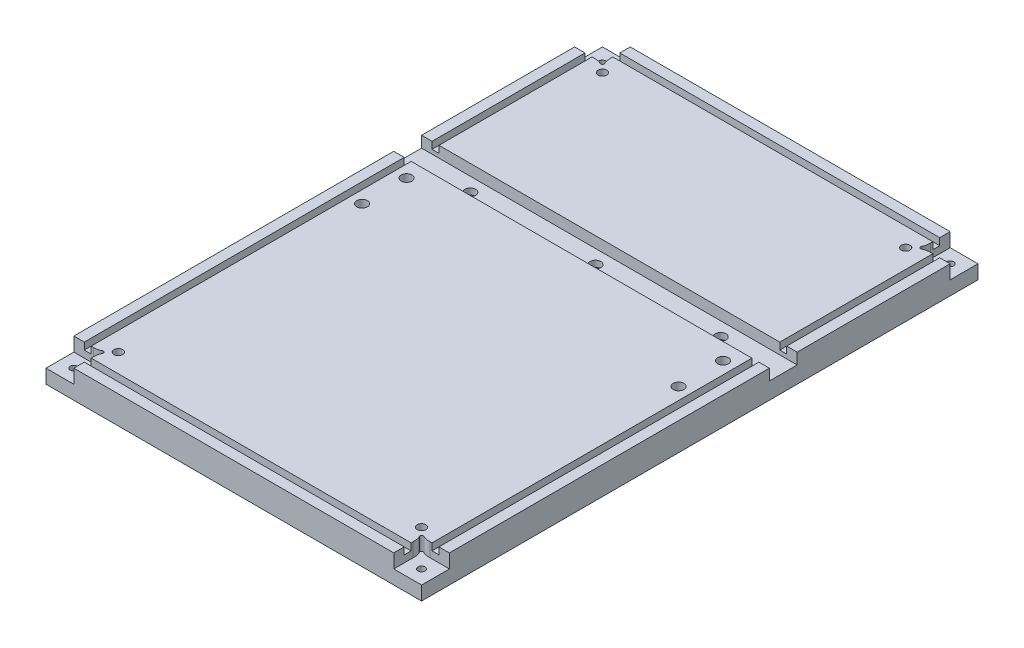
from build123d import *

# Parameters (mm, degrees)
BASE_W                                           = 342.9
BASE_H                                           = 508
BOSS_EXTRUDE1_DEPTH                              = 25.4
SKETCH2_W                                        = 406.4
SKETCH2_H                                        = 25.4
CUT_EXTRUDE1_DEPTH                               = 10.16
CBORE_FOR_3_8_SOCKET_HEAD_CAP_SCREW4_D           = 9.8044
CBORE_FOR_3_8_SOCKET_HEAD_CAP_SCREW4_DEPTH       = 15.24
CBORE_FOR_3_8_SOCKET_HEAD_CAP_SCREW4_CBORE_D     = 15.875
CBORE_FOR_3_8_SOCKET_HEAD_CAP_SCREW4_CBORE_DEPTH = 9.525
CBORE_FOR_3_8_SOCKET_HEAD_CAP_SCREW3_D           = 9.8044
CBORE_FOR_3_8_SOCKET_HEAD_CAP_SCREW3_DEPTH       = 25.4
CBORE_FOR_3_8_SOCKET_HEAD_CAP_SCREW3_CBORE_D     = 15.875
CBORE_FOR_3_8_SOCKET_HEAD_CAP_SCREW3_CBORE_DEPTH = 15.24
CBORE_FOR_1_4_SOCKET_HEAD_CAP_SCREW1_D           = 6.5278
CBORE_FOR_1_4_SOCKET_HEAD_CAP_SCREW1_DEPTH       = 25.4
CBORE_FOR_1_4_SOCKET_HEAD_CAP_SCREW1_CBORE_D     = 11.1125
CBORE_FOR_1_4_SOCKET_HEAD_CAP_SCREW1_CBORE_DEPTH = 6.35
CUT_EXTRUDE3_DEPTH                               = 12.7
SKETCH10_W                                       = 6.35
SKETCH10_H                                       = 457.2
SKETCH10_W_2                                     = 292.1
SKETCH10_H_2                                     = 6.35
CUT_EXTRUDE4_DEPTH                               = 6.35
F_3_8_16_TAPPED_HOLE2_D                          = 7.9375
F_3_8_16_TAPPED_HOLE2_DEPTH                      = 25.4
SKETCH19_R                                       = 9.525
CUT_EXTRUDE5_DEPTH                               = 1.27


with BuildPart() as part:
    # Base → Boss-Extrude1 (new body)
    with BuildSketch(Plane(origin=(0, 0, 0), x_dir=(1, 0, 0), z_dir=(0, 1, 0))):
        with Locations((-30.52641196, -120.249169435)):
            Rectangle(BASE_W, BASE_H)
    extrude(amount=BOSS_EXTRUDE1_DEPTH)

    # Sketch2 → Cut-Extrude1 (cut)
    with BuildSketch(Plane(origin=(0, 25.4, 0), x_dir=(1, 0, 0), z_dir=(0, 1, 0))):
        with Locations((-30.52641196, -44.049169435)):
            Rectangle(SKETCH2_W, SKETCH2_H)
    extrude(amount=-CUT_EXTRUDE1_DEPTH, mode=Mode.SUBTRACT)

    # CBORE for 3/8 Socket Head Cap Screw4
    with Locations(Plane(origin=(83.77358804, 0, 44.049169435), x_dir=(0, 0, -1), z_dir=(0, -1, 0))):
        with Locations((0, 0), (0, -114.3), (0, -228.6)):
            CounterBoreHole(CBORE_FOR_3_8_SOCKET_HEAD_CAP_SCREW4_D / 2, CBORE_FOR_3_8_SOCKET_HEAD_CAP_SCREW4_CBORE_D / 2, CBORE_FOR_3_8_SOCKET_HEAD_CAP_SCREW4_CBORE_DEPTH, depth=CBORE_FOR_3_8_SOCKET_HEAD_CAP_SCREW4_DEPTH)

    # CBORE for 3/8 Socket Head Cap Screw3
    with Locations(Plane(origin=(0, 0, 0), x_dir=(-1, 0, 0), z_dir=(0, -1, 0))):
        with Locations((-113.93608804, -71.989169435), (-113.93608804, -112.629169435), (174.98891196, -71.989169435), (174.98891196, -112.629169435)):
            CounterBoreHole(CBORE_FOR_3_8_SOCKET_HEAD_CAP_SCREW3_D / 2, CBORE_FOR_3_8_SOCKET_HEAD_CAP_SCREW3_CBORE_D / 2, CBORE_FOR_3_8_SOCKET_HEAD_CAP_SCREW3_CBORE_DEPTH, depth=CBORE_FOR_3_8_SOCKET_HEAD_CAP_SCREW3_DEPTH)

    # CBORE for 1/4 Socket Head Cap Screw1
    with Locations(Plane(origin=(128.22358804, 0, 361.549169435), x_dir=(0, 0, -1), z_dir=(0, -1, 0))):
        with Locations((0, 0), (0, -317.5), (482.6, -317.5), (482.6, 0)):
            CounterBoreHole(CBORE_FOR_1_4_SOCKET_HEAD_CAP_SCREW1_D / 2, CBORE_FOR_1_4_SOCKET_HEAD_CAP_SCREW1_CBORE_D / 2, CBORE_FOR_1_4_SOCKET_HEAD_CAP_SCREW1_CBORE_DEPTH, depth=CBORE_FOR_1_4_SOCKET_HEAD_CAP_SCREW1_DEPTH)

    # Sketch8 → Cut-Extrude3 (cut)
    with BuildSketch(Plane(origin=(0, 25.4, 0), x_dir=(1, 0, 0), z_dir=(0, 1, 0))):
        with BuildLine():
            Line((140.92358804, -374.249169435), (115.52358804, -374.249169435))
            Line((115.52358804, -374.249169435), (115.52358804, -356.469169435))
            add(Edge.make_bspline(
                [(115.52358804, -356.469169435), (115.52358804, -353.916782548), (115.309325815, -351.653056376), (114.148772711, -349.642919435)],
                knots=[0, 0, 0, 0, 1, 1, 1, 1], degree=3))
            ThreePointArc((114.148772711, -349.642919435), (114.401056025, -347.72663742), (116.31733804, -347.474354107))
            add(Edge.make_bspline(
                [(123.14358804, -348.849169435), (120.822481832, -348.849169435), (118.327474981, -348.634907211), (116.31733804, -347.474354107)],
                knots=[0, 0, 0, 0, 1, 1, 1, 1], degree=3))
            Line((123.14358804, -348.849169435), (140.92358804, -348.849169435))
            Line((140.92358804, -348.849169435), (140.92358804, -374.249169435))
        make_face()
        with BuildLine():
            Line((-201.97641196, -374.249169435), (-176.57641196, -374.249169435))
            Line((-176.57641196, -374.249169435), (-176.57641196, -356.469169435))
            add(Edge.make_bspline(
                [(-175.201596632, -349.642919435), (-176.794150567, -352.401303766), (-176.57641196, -354.968722974), (-176.57641196, -356.469169435)],
                knots=[0, 0, 0, 0, 1, 1, 1, 1], degree=3))
            ThreePointArc((-175.201596632, -349.642919435), (-175.453879945, -347.72663742), (-177.37016196, -347.474354107))
            add(Edge.make_bspline(
                [(-177.37016196, -347.474354107), (-180.128546291, -349.066908042), (-182.695965499, -348.849169435), (-184.19641196, -348.849169435)],
                knots=[0, 0, 0, 0, 1, 1, 1, 1], degree=3))
            Line((-184.19641196, -348.849169435), (-201.97641196, -348.849169435))
            Line((-201.97641196, -348.849169435), (-201.97641196, -374.249169435))
        make_face()
        with BuildLine():
            Line((-201.97641196, 133.750830565), (-176.57641196, 133.750830565))
            Line((-176.57641196, 133.750830565), (-176.57641196, 115.970830565))
            add(Edge.make_bspline(
                [(-176.57641196, 115.970830565), (-176.57641196, 113.418443678), (-176.362149736, 111.154717506), (-175.201596632, 109.144580565)],
                knots=[0, 0, 0, 0, 1, 1, 1, 1], degree=3))
            ThreePointArc((-175.201596632, 109.144580565), (-175.453879945, 107.22829855), (-177.37016196, 106.976015236))
            add(Edge.make_bspline(
                [(-177.37016196, 106.976015236), (-179.380298901, 108.13656834), (-181.875305752, 108.350830565), (-184.19641196, 108.350830565)],
                knots=[0, 0, 0, 0, 1, 1, 1, 1], degree=3))
            Line((-184.19641196, 108.350830565), (-201.97641196, 108.350830565))
            Line((-201.97641196, 108.350830565), (-201.97641196, 133.750830565))
        make_face()
        with BuildLine():
            Line((140.92358804, 133.750830565), (115.52358804, 133.750830565))
            Line((115.52358804, 133.750830565), (115.52358804, 115.970830565))
            add(Edge.make_bspline(
                [(114.148772711, 109.144580565), (115.309325815, 111.154717506), (115.52358804, 113.649724357), (115.52358804, 115.970830565)],
                knots=[0, 0, 0, 0, 1, 1, 1, 1], degree=3))
            ThreePointArc((114.148772711, 109.144580565), (114.401056025, 107.22829855), (116.31733804, 106.976015236))
            add(Edge.make_bspline(
                [(123.14358804, 108.350830565), (120.822481832, 108.350830565), (118.327474981, 108.13656834), (116.31733804, 106.976015236)],
                knots=[0, 0, 0, 0, 1, 1, 1, 1], degree=3))
            Line((123.14358804, 108.350830565), (140.92358804, 108.350830565))
            Line((140.92358804, 108.350830565), (140.92358804, 133.750830565))
        make_face()
    extrude(amount=-CUT_EXTRUDE3_DEPTH, mode=Mode.SUBTRACT)

    # Sketch10 → Cut-Extrude4 (cut)
    with BuildSketch(Plane(origin=(0, 25.4, 0), x_dir=(1, 0, 0), z_dir=(0, 1, 0))):
        with Locations((128.22358804, -120.249169435)):
            Rectangle(SKETCH10_W, SKETCH10_H)
        with Locations((-189.27641196, -120.249169435)):
            Rectangle(SKETCH10_W, SKETCH10_H)
        with Locations((-30.52641196, 121.050830565)):
            Rectangle(SKETCH10_W_2, SKETCH10_H_2)
        with Locations((-30.52641196, -361.549169435)):
            Rectangle(SKETCH10_W_2, SKETCH10_H_2)
    extrude(amount=-CUT_EXTRUDE4_DEPTH, mode=Mode.SUBTRACT)

    # 3/8-16 Tapped Hole2
    with Locations(Plane(origin=(0, 0, 0), x_dir=(-1, 0, 0), z_dir=(0, -1, 0))):
        with Locations((-107.90358804, -341.229169435), (168.95641196, -341.229169435), (168.95641196, 100.730830565), (-107.90358804, 100.730830565)):
            Hole(F_3_8_16_TAPPED_HOLE2_D / 2, depth=F_3_8_16_TAPPED_HOLE2_DEPTH)

    # Sketch19 → Cut-Extrude5 (cut)
    with BuildSketch(Plane.XZ):
        with Locations((-168.95641196, -100.730830565)):
            Circle(SKETCH19_R)
        with Locations((-168.95641196, 341.229169435)):
            Circle(SKETCH19_R)
        with Locations((107.90358804, 341.229169435)):
            Circle(SKETCH19_R)
        with Locations((108.217263786, -100.730830565)):
            Circle(SKETCH19_R)
    extrude(amount=-CUT_EXTRUDE5_DEPTH, mode=Mode.SUBTRACT)


solid = part.part
